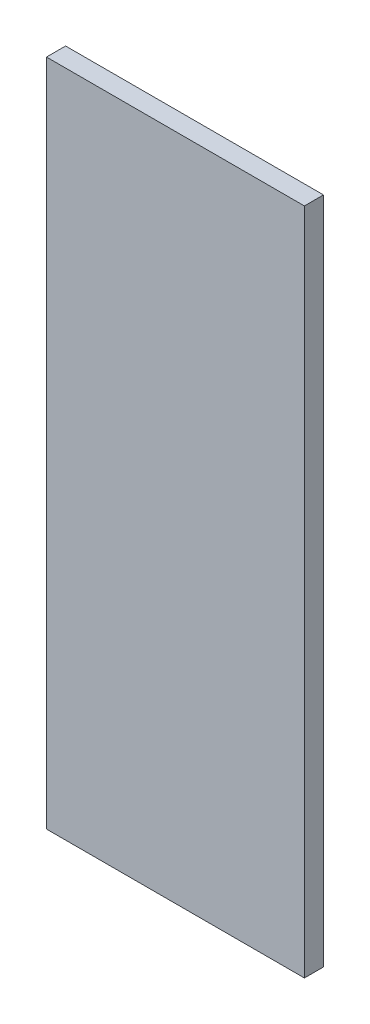
from build123d import *

# Parameters (mm, degrees)
SKETCH3_W           = 135
SKETCH3_H           = 350
BOSS_EXTRUDE1_DEPTH = 10


with BuildPart() as part:
    # Sketch3 → Boss-Extrude1 (new body)
    with BuildSketch(Plane.XY):
        with Locations((-67.5, 175)):
            Rectangle(SKETCH3_W, SKETCH3_H)
    extrude(amount=BOSS_EXTRUDE1_DEPTH)


solid = part.part
